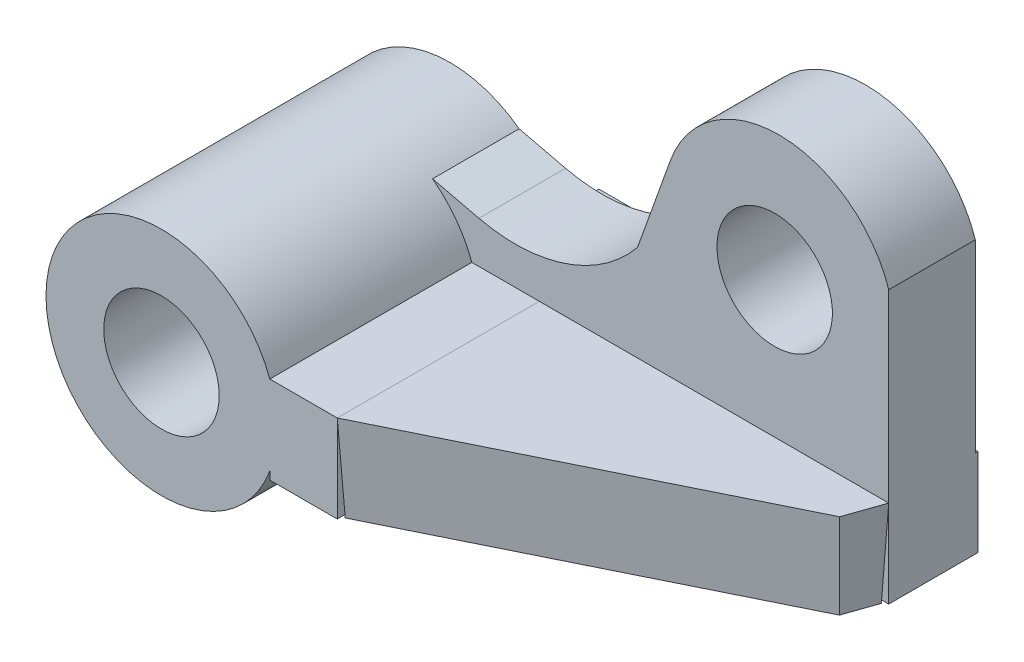
from build123d import *

# Parameters (mm, degrees)
SKETCH1_R           = 20
SKETCH1_R_2         = 10
BOSS_EXTRUDE1_DEPTH = 25
SKETCH3_R           = 10
BOSS_EXTRUDE2_DEPTH = 15
SKETCH5_W           = 11.686039437
SKETCH5_H           = 15.160748225
BOSS_EXTRUDE4_DEPTH = 57
BOSS_EXTRUDE7_DEPTH = 15.160748
BOSS_EXTRUDE7_TAPER = 2
SKETCH9_W           = 15.466194976
SKETCH9_H           = 15.160748225
BOSS_EXTRUDE8_DEPTH = 71


with BuildPart() as part:
    # Sketch1 → Boss-Extrude1 (new body, symmetric)
    with BuildSketch(Plane.XY):
        Circle(SKETCH1_R)
        Circle(SKETCH1_R_2, mode=Mode.SUBTRACT)
    extrude(amount=BOSS_EXTRUDE1_DEPTH, both=True)

    # Sketch3 → Boss-Extrude2 (add)
    with BuildSketch(Plane(origin=(0, 0, -25), x_dir=(-1, 0, 0), z_dir=(0, 0, -1))):
        with BuildLine():
            ThreePointArc((-18.773167468, 6.896969133), (-16.030390847, 11.959371609), (-11.959065832, 16.030618966))
            Line((-11.959065832, 16.030618966), (-20, 14.130044659))
            ThreePointArc((-20, 14.130044659), (-35.086276942, 14.859068724), (-47.474240285, 23.499994155))
            Line((-47.474240285, 23.499994155), (-53.159793003, 39.376827298))
            ThreePointArc((-53.159793003, 39.376827298), (-72.24261099, 52.632447176), (-90.982996354, 38.896969133))
            Line((-90.982996354, 38.896969133), (-90.982996354, 6.896969133))
            Line((-90.982996354, 6.896969133), (-18.773167468, 6.896969133))
        make_face()
        with Locations((-71.225862734, 30.503301639)):
            Circle(SKETCH3_R, mode=Mode.SUBTRACT)
    extrude(amount=-BOSS_EXTRUDE2_DEPTH)

    # Sketch5 → Boss-Extrude4 (add)
    with BuildSketch(Plane.XY.offset(25)):
        with Locations((24.616187186, -0.683404979)):
            Rectangle(SKETCH5_W, SKETCH5_H)
    extrude(amount=-BOSS_EXTRUDE4_DEPTH)

    # Sketch9 → Boss-Extrude8 (add)
    with BuildSketch(Plane(origin=(90.982996354, 0, 0), x_dir=(0, 0, -1), z_dir=(1, 0, 0))):
        with Locations((17.733097488, -0.683404979)):
            Rectangle(SKETCH9_W, SKETCH9_H)
    extrude(amount=-BOSS_EXTRUDE8_DEPTH)


with BuildPart() as body_2:
    # Sketch8 → Boss-Extrude7 (new body)
    with BuildSketch(Plane(origin=(0, 6.896969133, 0), x_dir=(1, 0, 0), z_dir=(0, 1, 0))):
        Polygon((30.459206905, -25), (88.794906921, 3.693901382), (90.982996354, 10), (30.459206905, 10), align=None)
    extrude(amount=-BOSS_EXTRUDE7_DEPTH, taper=BOSS_EXTRUDE7_TAPER)


solid = Compound([part.part, body_2.part])
